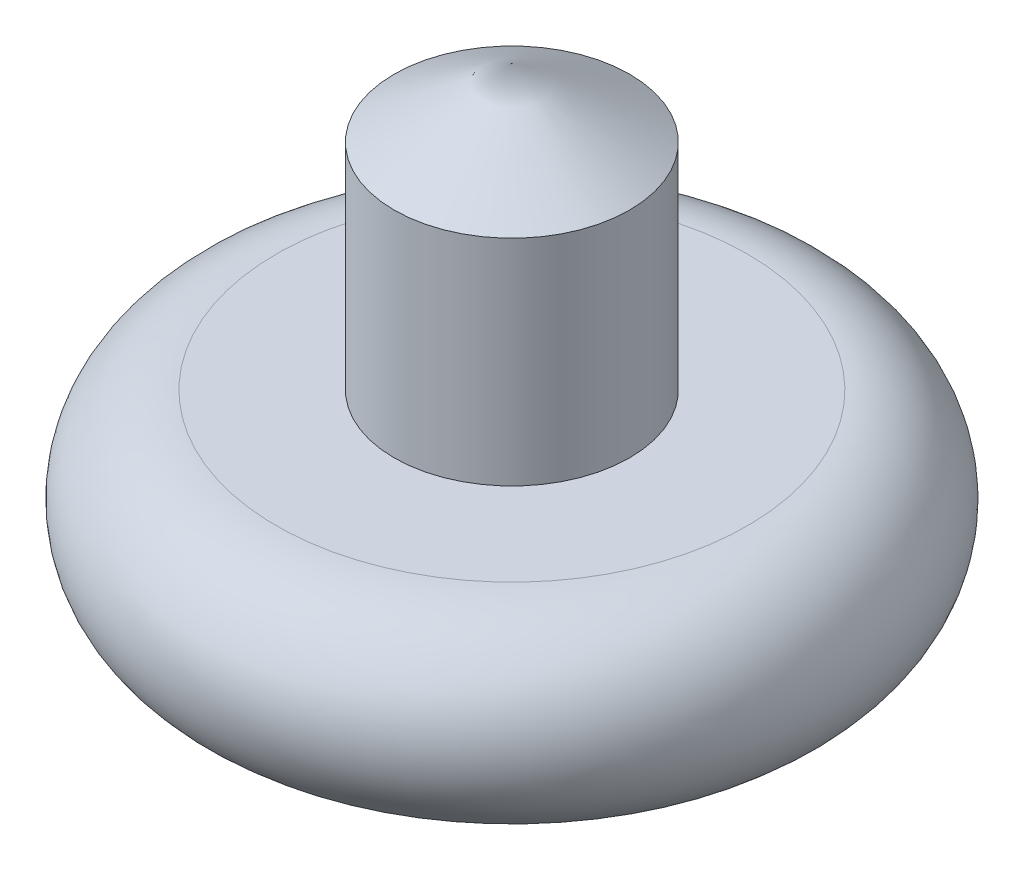
from build123d import *


with BuildPart() as part:
    # Sketch4 → Revolve1 (revolve)
    with BuildSketch(Plane.XY):
        with BuildLine():
            Line((0, 0), (0, 200))
            Line((0, 200), (50, 171.132486541))
            Line((50, 171.132486541), (50, 80))
            Line((50, 80), (100, 80))
            ThreePointArc((100, 80), (140, 40), (100, 0))
            Line((100, 0), (0, 0))
        make_face()
    revolve(axis=Axis((0, 0, 0), (0, 1, 0)))


solid = part.part
